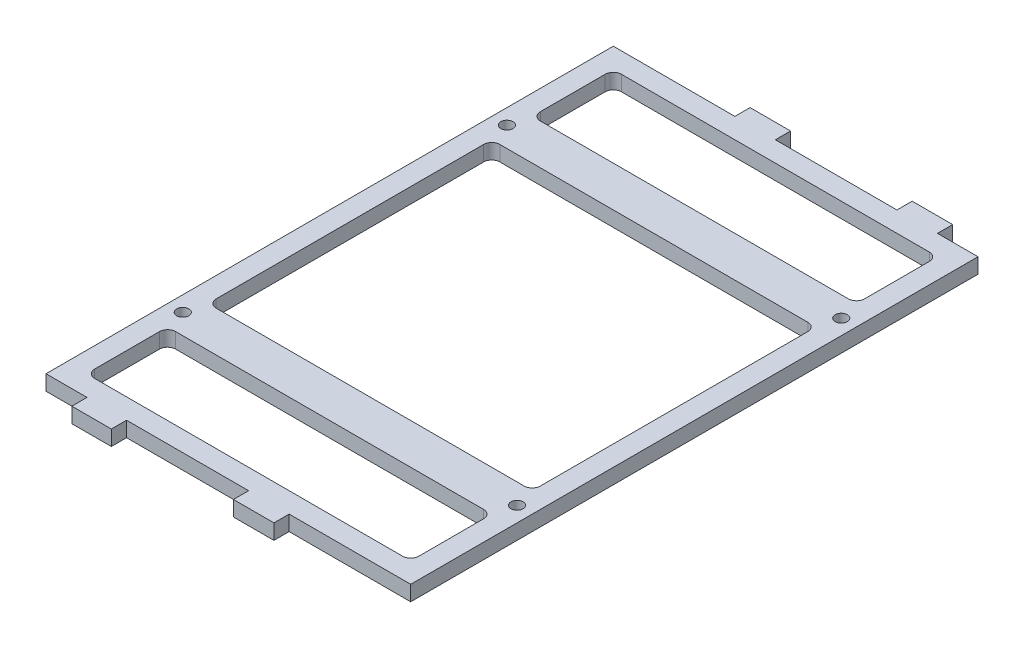
from build123d import *

# Parameters (mm, degrees)
SKETCH1_W                 = 114.3
SKETCH1_H                 = 177.8
SKETCH1_W_2               = 101.6
SKETCH1_H_2               = 165.1
BOSS_EXTRUDE1_DEPTH       = 4.7625
SKETCH2_W                 = 12.38677804
SKETCH2_H                 = 4.7625
SKETCH2_W_2               = 12.7
BOSS_EXTRUDE2_DEPTH       = 4.7625
SKETCH3_W                 = 12.7
SKETCH3_H                 = 4.7625
BOSS_EXTRUDE3_DEPTH       = 4.7625
FILLET1_R                 = 2.54
SKETCH4_W                 = 114.3
SKETCH4_H                 = 12.7
BOSS_EXTRUDE4_DEPTH       = 4.7625
F_6_CLEARANCE_HOLE1_D     = 3.7973
F_6_CLEARANCE_HOLE1_DEPTH = 25.4
F_6_CLEARANCE_HOLE1_TIP   = 1.140824014
FILLET2_R                 = 2.54


with BuildPart() as part:
    # Sketch1 → Boss-Extrude1 (new body)
    with BuildSketch(Plane(origin=(0, 0, 0), x_dir=(1, 0, 0), z_dir=(0, 1, 0))):
        Rectangle(SKETCH1_W, SKETCH1_H)
        Rectangle(SKETCH1_W_2, SKETCH1_H_2, mode=Mode.SUBTRACT)
    extrude(amount=BOSS_EXTRUDE1_DEPTH)

    # Sketch2 → Boss-Extrude2 (add)
    with BuildSketch(Plane.XY.offset(88.9)):
        with Locations((-38.1, 2.38125)):
            Rectangle(SKETCH2_W, SKETCH2_H)
        with Locations((12.7, 2.38125)):
            Rectangle(SKETCH2_W_2, SKETCH2_H)
    extrude(amount=BOSS_EXTRUDE2_DEPTH)

    # Sketch3 → Boss-Extrude3 (add)
    with BuildSketch(Plane(origin=(0, 0, -88.9), x_dir=(-1, 0, 0), z_dir=(0, 0, -1))):
        with Locations((-38.1, 2.38125)):
            Rectangle(SKETCH3_W, SKETCH3_H)
        with Locations((12.7, 2.38125)):
            Rectangle(SKETCH3_W, SKETCH3_H)
    extrude(amount=BOSS_EXTRUDE3_DEPTH)

    # Fillet1
    fillet1_edges = [part.edges().sort_by_distance(p)[0] for p in [
        (50.8, 2.38125, 82.55),
        (50.8, 2.38125, -82.55),
        (-50.8, 2.38125, -82.55),
        (-50.8, 2.38125, 82.55),
    ]]
    fillet(fillet1_edges, radius=FILLET1_R)

    # Sketch4 → Boss-Extrude4 (add)
    with BuildSketch(Plane(origin=(0, 4.7625, 0), x_dir=(1, 0, 0), z_dir=(0, 1, 0))):
        with Locations((0, -50.8)):
            Rectangle(SKETCH4_W, SKETCH4_H)
        with Locations((0, 50.8)):
            Rectangle(SKETCH4_W, SKETCH4_H)
    extrude(amount=-BOSS_EXTRUDE4_DEPTH)

    # #6 Clearance Hole1
    with Locations(Plane(origin=(0, 4.7625, 0), x_dir=(-1, 0, 0), z_dir=(0, 1, 0))):
        with Locations((52.3875, -50.8), (-52.3875, -50.8), (52.3875, 50.8), (-52.3875, 50.8)):
            Hole(F_6_CLEARANCE_HOLE1_D / 2, depth=F_6_CLEARANCE_HOLE1_DEPTH)
            with Locations((0, 0, -(F_6_CLEARANCE_HOLE1_DEPTH + F_6_CLEARANCE_HOLE1_TIP / 2))):  # 118° drill point
                Cone(0, F_6_CLEARANCE_HOLE1_D / 2, F_6_CLEARANCE_HOLE1_TIP, mode=Mode.SUBTRACT)

    # Fillet2
    fillet2_edges = [part.edges().sort_by_distance(p)[0] for p in [
        (-50.8, 2.38125, 57.15),
        (-50.8, 2.38125, 44.45),
        (50.8, 2.38125, 44.45),
        (50.8, 2.38125, 57.15),
        (50.8, 2.38125, -57.15),
        (-50.8, 2.38125, -57.15),
        (50.8, 2.38125, -44.45),
        (-50.8, 2.38125, -44.45),
    ]]
    fillet(fillet2_edges, radius=FILLET2_R)


solid = part.part
